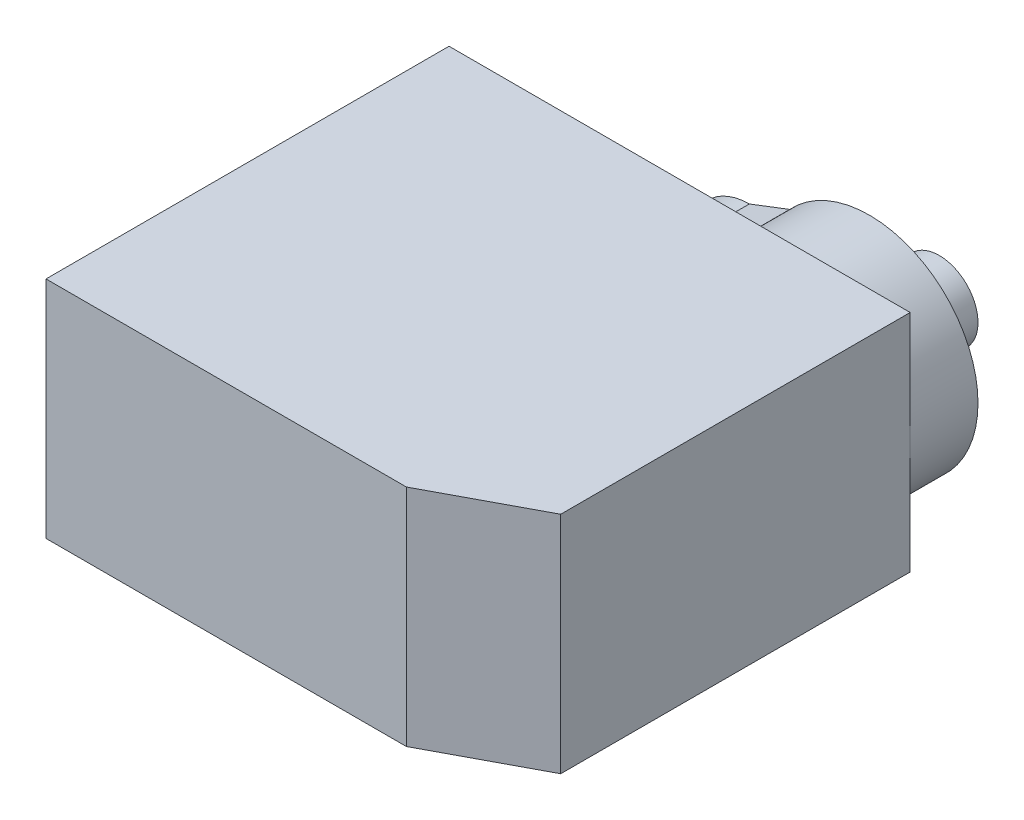
from build123d import *

# Parameters (mm, degrees)
EXTRUDE_1_DEPTH = 11.6
EXTRUDE_2_DEPTH = 3.5
SKETCH_3_R      = 1
EXTRUDE_3_DEPTH = 1
SKETCH_3_3_R    = 1
SKETCH_3_3_R_2  = 2.8
EXTRUDE_4_DEPTH = 0.4
SKETCH_5_R      = 2
EXTRUDE_5_DEPTH = 3.2


with BuildPart() as part:
    # ｽｹｯﾁ1 → ﾎﾞｽ - 押し出し1 (new body)
    with BuildSketch(Plane(origin=(0, 0, 0), x_dir=(1, 0, 0), z_dir=(0, 1, 0))):
        Polygon((0, 0), (18.6, 0), (23.8, 2.764889045), (23.8, 20.8), (0, 20.8), align=None)
    extrude(amount=EXTRUDE_1_DEPTH)

    # ｽｹｯﾁ2 → ﾎﾞｽ - 押し出し2 (add)
    with BuildSketch(Plane(origin=(0, 0, -20.8), x_dir=(-1, 0, 0), z_dir=(0, 0, -1))):
        with BuildLine():
            Line((-14.08660724, 9.6), (-12, 8.8))
            ThreePointArc((-12, 8.8), (-9, 5.8), (-12, 2.8))
            Line((-12, 2.8), (-14.08660724, 2))
            ThreePointArc((-14.08660724, 2), (-23.8, 5.8), (-14.08660724, 9.6))
        make_face()
    extrude(amount=EXTRUDE_2_DEPTH)

    # ｽｹｯﾁ3 → ﾎﾞｽ - 押し出し3 (add)
    with BuildSketch(Plane(origin=(0, 0, -24.3), x_dir=(-1, 0, 0), z_dir=(0, 0, -1))):
        with Locations((-11.2, 5.8)):
            Circle(SKETCH_3_R)
    extrude(amount=EXTRUDE_3_DEPTH)

    # ｽｹｯﾁ3<3> → ﾎﾞｽ - 押し出し4 (add)
    with BuildSketch(Plane(origin=(0, 0, -24.3), x_dir=(-1, 0, 0), z_dir=(0, 0, -1))):
        with Locations((-11.2, 5.8)):
            Circle(SKETCH_3_3_R)
        with Locations((-18.2, 5.8)):
            Circle(SKETCH_3_3_R_2)
    extrude(amount=EXTRUDE_4_DEPTH)

    # ｽｹｯﾁ5 → ﾎﾞｽ - 押し出し5 (add)
    with BuildSketch(Plane(origin=(0, 0, -24.7), x_dir=(-1, 0, 0), z_dir=(0, 0, -1))):
        with Locations((-18.2, 5.8)):
            Circle(SKETCH_5_R)
    extrude(amount=EXTRUDE_5_DEPTH)


solid = part.part
